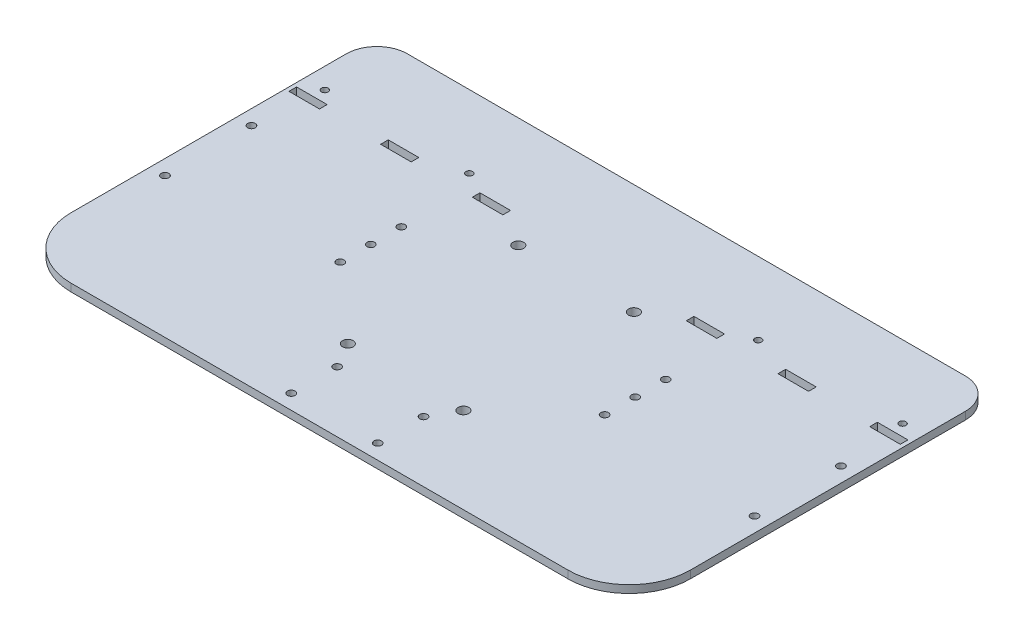
from build123d import *

# Parameters (mm, degrees)
SKETCH1_R           = 4.445
SKETCH1_R_2         = 3.175
SKETCH1_R_3         = 2.794
SKETCH1_W           = 25.4
SKETCH1_H           = 6.35
BOSS_EXTRUDE1_DEPTH = 6.35


with BuildPart() as part:
    # Sketch1 → Boss-Extrude1 (new body)
    with BuildSketch(Plane(origin=(0, 0, 0), x_dir=(1, 0, 0), z_dir=(0, 1, 0))):
        with BuildLine():
            Line((50.8, 0), (463.677487426, 0))
            ThreePointArc((463.677487426, 0), (499.59851191, 14.878975516), (514.477487426, 50.8))
            Line((514.477487426, 50.8), (514.477487426, 279.4))
            ThreePointArc((514.477487426, 279.4), (507.037999668, 297.360512242), (489.077487426, 304.8))
            Line((489.077487426, 304.8), (25.4, 304.8))
            ThreePointArc((25.4, 304.8), (7.439487758, 297.360512242), (0, 279.4))
            Line((0, 279.4), (0, 50.8))
            ThreePointArc((0, 50.8), (14.878975516, 14.878975516), (50.8, 0))
        make_face()
        with Locations((305.32695, 213.055054)):
            Circle(SKETCH1_R, mode=Mode.SUBTRACT)
        with Locations((305.32695, 71.425054)):
            Circle(SKETCH1_R, mode=Mode.SUBTRACT)
        with Locations((502.173875, 116.4574125)):
            Circle(SKETCH1_R_2, mode=Mode.SUBTRACT)
        with Locations((502.173875, 188.2917875)):
            Circle(SKETCH1_R_2, mode=Mode.SUBTRACT)
        with Locations((12.303125, 116.4574125)):
            Circle(SKETCH1_R_2, mode=Mode.SUBTRACT)
        with Locations((12.303125, 188.2917875)):
            Circle(SKETCH1_R_2, mode=Mode.SUBTRACT)
        with Locations((209.27695, 71.425054)):
            Circle(SKETCH1_R, mode=Mode.SUBTRACT)
        with Locations((209.27695, 213.055054)):
            Circle(SKETCH1_R, mode=Mode.SUBTRACT)
        with Locations((221.3848125, 50.403125)):
            Circle(SKETCH1_R_2, mode=Mode.SUBTRACT)
        with Locations((221.3848125, 12.303125)):
            Circle(SKETCH1_R_2, mode=Mode.SUBTRACT)
        with Locations((293.2191875, 50.403125)):
            Circle(SKETCH1_R_2, mode=Mode.SUBTRACT)
        with Locations((293.2191875, 12.303125)):
            Circle(SKETCH1_R_2, mode=Mode.SUBTRACT)
        with Locations((147.3962, 177.7746)):
            Circle(SKETCH1_R_2, mode=Mode.SUBTRACT)
        with Locations((147.3962, 126.9746)):
            Circle(SKETCH1_R_2, mode=Mode.SUBTRACT)
        with Locations((147.3962, 152.3746)):
            Circle(SKETCH1_R_2, mode=Mode.SUBTRACT)
        with Locations((367.081287426, 152.3746)):
            Circle(SKETCH1_R_2, mode=Mode.SUBTRACT)
        with Locations((367.081287426, 126.9746)):
            Circle(SKETCH1_R_2, mode=Mode.SUBTRACT)
        with Locations((367.081287426, 177.7746)):
            Circle(SKETCH1_R_2, mode=Mode.SUBTRACT)
        with Locations((497.175487426, 244.4496)):
            Circle(SKETCH1_R_3, mode=Mode.SUBTRACT)
        with Locations((377.175487426, 244.4496)):
            Circle(SKETCH1_R_3, mode=Mode.SUBTRACT)
        with Locations((137.175487426, 244.4496)):
            Circle(SKETCH1_R_3, mode=Mode.SUBTRACT)
        with Locations((17.175487426, 244.4496)):
            Circle(SKETCH1_R_3, mode=Mode.SUBTRACT)
        with Locations((498.475487426, 231.7496)):
            Rectangle(SKETCH1_W, SKETCH1_H, mode=Mode.SUBTRACT)
        with Locations((422.275487426, 231.7496)):
            Rectangle(SKETCH1_W, SKETCH1_H, mode=Mode.SUBTRACT)
        with Locations((346.075487426, 231.7496)):
            Rectangle(SKETCH1_W, SKETCH1_H, mode=Mode.SUBTRACT)
        with Locations((168.275487426, 231.7496)):
            Rectangle(SKETCH1_W, SKETCH1_H, mode=Mode.SUBTRACT)
        with Locations((92.075487426, 231.7496)):
            Rectangle(SKETCH1_W, SKETCH1_H, mode=Mode.SUBTRACT)
        with Locations((15.875487426, 231.7496)):
            Rectangle(SKETCH1_W, SKETCH1_H, mode=Mode.SUBTRACT)
    extrude(amount=BOSS_EXTRUDE1_DEPTH)


solid = part.part
